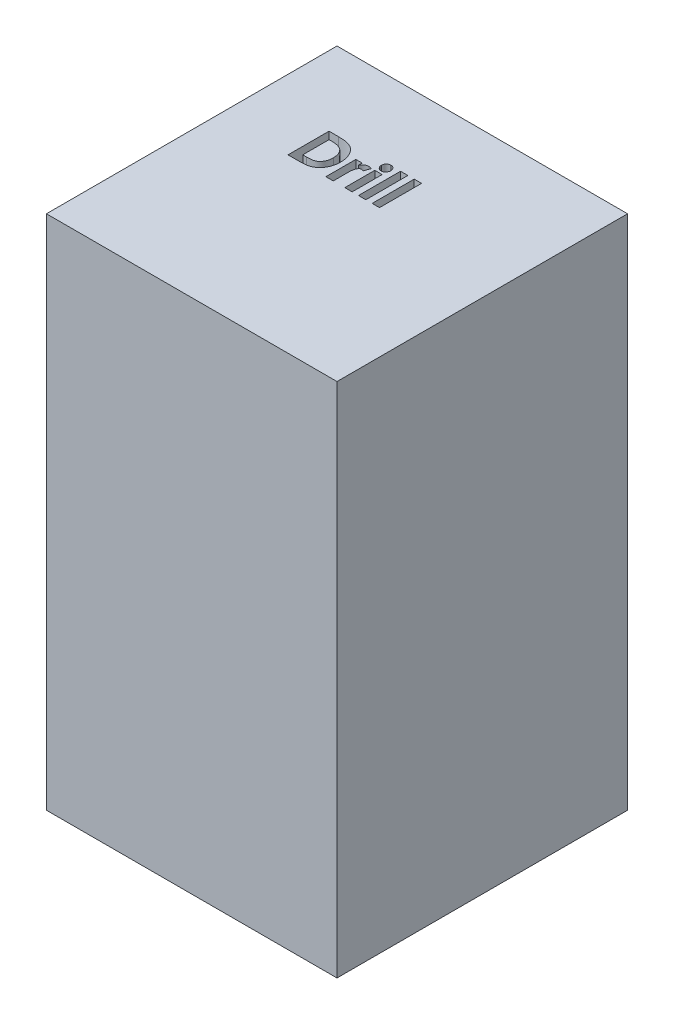
from build123d import *

# Parameters (mm, degrees)
SKETCH1_W           = 90
SKETCH1_H           = 90
BOSS_EXTRUDE1_DEPTH = 160
SKETCH2_W           = 2.27948718
SKETCH2_H           = 9.280769231
SKETCH2_W_2         = 2.279487179
SKETCH2_H_2         = 13.025641026
CUT_EXTRUDE1_DEPTH  = 150


with BuildPart() as part:
    # Sketch1 → Boss-Extrude1 (new body)
    with BuildSketch(Plane(origin=(0, 0, 0), x_dir=(1, 0, 0), z_dir=(0, 1, 0))):
        with Locations((45, 45)):
            Rectangle(SKETCH1_W, SKETCH1_H)
    extrude(amount=BOSS_EXTRUDE1_DEPTH)

    # Sketch2 → Cut-Extrude1 (cut)
    with BuildSketch(Plane(origin=(0, 160, 0), x_dir=(1, 0, 0), z_dir=(0, 1, 0))):
        with BuildLine():
            Line((21.611077672, 65.922158503), (24.483333281, 65.922158503))
            add(Edge.make_bspline(
                [(24.483333281, 65.922158503), (24.707258642, 65.920593189), (25.140108898, 65.917567417), (25.767223285, 65.88347425), (26.350359864, 65.831041379), (26.889894536, 65.758910462), (27.384721167, 65.663461507), (27.834201687, 65.543739501), (28.239844663, 65.405540361), (28.606097885, 65.242921031), (28.940451848, 65.053323041), (29.257931608, 64.842126103), (29.557913799, 64.601593454), (29.844608198, 64.336365449), (30.114314952, 64.041589823), (30.371525645, 63.722149129), (30.609942592, 63.373411035), (30.836772622, 63.003737182), (31.0419102, 62.611560926), (31.220838862, 62.200220391), (31.370728486, 61.772362706), (31.492521568, 61.327531886), (31.589604711, 60.867204634), (31.657531829, 60.390452053), (31.69952505, 59.897715535), (31.703784912, 59.563763804), (31.705949466, 59.394073568)],
                knots=[0, 0, 0, 0, 1.44355588, 2.790409838, 4.047694926, 5.217575253, 6.298404546, 7.294384826, 8.214239204, 9.058592145, 9.873746385, 10.689560431, 11.514393297, 12.350027578, 13.205127629, 14.088021785, 14.991911688, 15.926770944, 16.882954281, 17.842803888, 18.816321264, 19.80318086, 20.814351908, 21.847355356, 22.906180909, 24, 24, 24, 24], degree=3))
            add(Edge.make_bspline(
                [(31.705949466, 59.394073568), (31.700281493, 59.154629598), (31.689123756, 58.683270128), (31.595137212, 57.991555537), (31.443129146, 57.328478111), (31.229391999, 56.699224698), (30.964415152, 56.109398894), (30.647870638, 55.569402028), (30.284399734, 55.082132531), (29.8782369, 54.650016606), (29.438461471, 54.278607111), (28.981446119, 53.960522058), (28.502738681, 53.709685452), (28.080930527, 53.550617534), (27.715170235, 53.451691051), (27.394036655, 53.393224547), (27.029261674, 53.339607236), (26.617444083, 53.298172932), (26.160390436, 53.261223715), (25.656278912, 53.241146949), (25.106741679, 53.224466136), (24.725036111, 53.22294787), (24.526582479, 53.222158503)],
                knots=[0, 0, 0, 0, 1.315458931, 2.589557908, 3.828601765, 5.048913369, 6.235739168, 7.376350998, 8.481830359, 9.569842114, 10.627874879, 11.640079404, 12.624025415, 13.590060155, 14.111227486, 14.704434459, 15.382649715, 16.137166398, 16.978595427, 17.902333227, 18.909396075, 20, 20, 20, 20], degree=3))
            Line((24.526582479, 53.222158503), (21.611077672, 53.222158503))
            Line((21.611077672, 53.222158503), (21.611077672, 65.922158503))
        make_face()
        with BuildLine():
            Line((23.890564851, 63.642671324), (23.890564851, 55.501645683))
            Line((23.890564851, 55.501645683), (25.081189851, 55.501645683))
            add(Edge.make_bspline(
                [(25.081189851, 55.501645683), (25.222855941, 55.501905274), (25.495326993, 55.502404554), (25.888713514, 55.52618568), (26.252496301, 55.550055373), (26.585673943, 55.595360849), (26.890671205, 55.645827961), (27.163298221, 55.716059857), (27.409175021, 55.789832515), (27.625298266, 55.883754252), (27.823249549, 55.989469418), (28.006529826, 56.11332699), (28.183446608, 56.250866153), (28.350692293, 56.406132129), (28.508899865, 56.577068904), (28.657133269, 56.764557241), (28.797371028, 56.968025107), (28.926013504, 57.188548286), (29.043567688, 57.423798005), (29.147851421, 57.671495526), (29.234318024, 57.933703637), (29.306183771, 58.207967754), (29.357539996, 58.496675658), (29.400027477, 58.797688929), (29.421931011, 59.112200156), (29.424937135, 59.326204107), (29.426462287, 59.434778696)],
                knots=[0, 0, 0, 0, 1.50275155, 2.890291501, 4.180787663, 5.369391935, 6.45668281, 7.458360028, 8.354766181, 9.177074746, 9.954075863, 10.732690366, 11.5210699, 12.329727389, 13.151100085, 13.990027547, 14.863562427, 15.770965086, 16.696477834, 17.652329173, 18.619756807, 19.62365428, 20.657822005, 21.729286259, 22.847956731, 24, 24, 24, 24], degree=3))
            add(Edge.make_bspline(
                [(29.426462287, 59.434778696), (29.423424701, 59.601158989), (29.417501644, 59.92558767), (29.360380967, 60.398125124), (29.267399399, 60.843089927), (29.134723662, 61.258830694), (28.967481782, 61.646515876), (28.758139585, 62.002860957), (28.515706351, 62.333852044), (28.323996765, 62.528022037), (28.228205075, 62.625043119)],
                knots=[0, 0, 0, 0, 1.13821349, 2.219428113, 3.251817212, 4.244760574, 5.201143372, 6.134805572, 7.068016741, 8, 8, 8, 8], degree=3))
            add(Edge.make_bspline(
                [(28.228205075, 62.625043119), (28.133745399, 62.707718197), (27.940822207, 62.876572683), (27.602112479, 63.078903538), (27.228871901, 63.256671027), (26.812561848, 63.39762082), (26.357205771, 63.509089926), (25.86009156, 63.585967442), (25.32388137, 63.635368119), (24.952407444, 63.640184767), (24.760636966, 63.642671324)],
                knots=[0, 0, 0, 0, 0.813307809, 1.661089106, 2.549956539, 3.493439533, 4.508053171, 5.589449661, 6.755572447, 8, 8, 8, 8], degree=3))
            Line((24.760636966, 63.642671324), (23.890564851, 63.642671324))
        make_face(mode=Mode.SUBTRACT)
        with BuildLine():
            Line((33.334154595, 62.502927734), (35.288000749, 62.502927734))
            Line((35.288000749, 62.502927734), (35.288000749, 61.360640074))
            add(Edge.make_bspline(
                [(35.288000749, 61.360640074), (35.343271305, 61.462155493), (35.451299902, 61.66057159), (35.649757493, 61.926905908), (35.877753612, 62.151205239), (36.127095654, 62.338161009), (36.398539324, 62.483874674), (36.684815845, 62.587714031), (36.983476127, 62.655195223), (37.187212046, 62.662205243), (37.290184242, 62.665748247)],
                knots=[0, 0, 0, 0, 1.09866127, 2.147379032, 3.14564304, 4.131443017, 5.102343063, 6.064490016, 7.021754664, 8, 8, 8, 8], degree=3))
            add(Edge.make_bspline(
                [(37.290184242, 62.665748247), (37.364954905, 62.662247019), (37.517214674, 62.655117269), (37.749279987, 62.613671922), (37.984693596, 62.538730853), (38.139616036, 62.471256381), (38.218769979, 62.436781901)],
                knots=[0, 0, 0, 0, 0.931404136, 1.896671404, 2.925354185, 4, 4, 4, 4], degree=3))
            Line((38.218769979, 62.436781901), (37.511518377, 60.505832382))
            add(Edge.make_bspline(
                [(37.511518377, 60.505832382), (37.448300183, 60.536376356), (37.329474315, 60.593787271), (37.156959787, 60.661538064), (37.000395699, 60.702876287), (36.901136942, 60.709044312), (36.855148184, 60.711902093)],
                knots=[0, 0, 0, 0, 1.214386998, 2.282580073, 3.20428172, 4, 4, 4, 4], degree=3))
            add(Edge.make_bspline(
                [(36.855148184, 60.711902093), (36.811725854, 60.710008376), (36.726306649, 60.706283109), (36.600230293, 60.674358835), (36.481492619, 60.619306412), (36.364371666, 60.548778795), (36.258106978, 60.450740133), (36.151907928, 60.337242974), (36.058319638, 60.197115636), (35.959556851, 60.041146791), (35.875463869, 59.850241066), (35.803356726, 59.622338971), (35.739108683, 59.354803523), (35.694897257, 59.046214239), (35.65216514, 58.699557253), (35.626729934, 58.312288146), (35.607772753, 57.8856315), (35.606613649, 57.587809763), (35.606009563, 57.432595202)],
                knots=[0, 0, 0, 0, 0.544232178, 1.070598461, 1.618251235, 2.182094276, 2.777567932, 3.425210017, 4.127676488, 4.886675562, 5.738955394, 6.734782583, 7.883056018, 9.186093582, 10.642914445, 12.264202625, 14.053029461, 16, 16, 16, 16], degree=3))
            Line((35.606009563, 57.432595202), (35.613641774, 56.979750651))
            Line((35.613641774, 56.979750651), (35.613641774, 53.222158503))
            Line((35.613641774, 53.222158503), (33.334154595, 53.222158503))
            Line((33.334154595, 53.222158503), (33.334154595, 62.502927734))
        make_face()
        with BuildLine():
            add(Edge.make_bspline(
                [(40.330348505, 66.410620042), (40.428594386, 66.405799727), (40.62150964, 66.396334575), (40.897886993, 66.304070393), (41.151545391, 66.159264517), (41.375786449, 65.960587403), (41.562289193, 65.723330591), (41.704784215, 65.457705815), (41.784162256, 65.163402119), (41.795186692, 64.960100203), (41.800821261, 64.856192959)],
                knots=[0, 0, 0, 0, 0.989868614, 1.943702388, 2.910836514, 3.924849579, 4.949916355, 5.946401046, 6.950409252, 8, 8, 8, 8], degree=3))
            add(Edge.make_bspline(
                [(41.800821261, 64.856192959), (41.795388287, 64.753051453), (41.784801879, 64.552075317), (41.702957281, 64.261766931), (41.566181513, 63.996271169), (41.378168214, 63.762538061), (41.156358222, 63.56706076), (40.908242454, 63.41962602), (40.634513598, 63.332494474), (40.444591807, 63.322238088), (40.348156999, 63.317030298)],
                knots=[0, 0, 0, 0, 1.05296456, 2.051751585, 3.055639087, 4.085634717, 5.099016424, 6.062201612, 7.016062274, 8, 8, 8, 8], degree=3))
            add(Edge.make_bspline(
                [(40.348156999, 63.317030298), (40.249053512, 63.321833381), (40.054459903, 63.331264425), (39.775815687, 63.423744483), (39.518774135, 63.567409919), (39.295505833, 63.770146314), (39.106867216, 64.009089016), (38.970596432, 64.280897766), (38.885355686, 64.577213904), (38.875237684, 64.783526859), (38.870052031, 64.889265875)],
                knots=[0, 0, 0, 0, 0.989065327, 1.942068821, 2.907541208, 3.917690034, 4.939857478, 5.938239964, 6.943311734, 8, 8, 8, 8], degree=3))
            add(Edge.make_bspline(
                [(38.870052031, 64.889265875), (38.87569544, 64.990655977), (38.886781102, 65.189822194), (38.966634626, 65.477582657), (39.105862243, 65.738741864), (39.291021589, 65.971655469), (39.513293056, 66.166626507), (39.766799179, 66.307034534), (40.041316502, 66.395487942), (40.233009707, 66.405523927), (40.330348505, 66.410620042)],
                knots=[0, 0, 0, 0, 1.038616768, 2.040212704, 3.031499824, 4.052181184, 5.074969369, 6.039807101, 7.004644834, 8, 8, 8, 8], degree=3))
        make_face()
        with Locations((40.335436646, 57.862543118)):
            Rectangle(SKETCH2_W, SKETCH2_H)
        with Locations((44.56876998, 59.734979016)):
            Rectangle(SKETCH2_W_2, SKETCH2_H_2)
        with Locations((48.802103313, 59.734979016)):
            Rectangle(SKETCH2_W_2, SKETCH2_H_2)
    extrude(amount=-CUT_EXTRUDE1_DEPTH, mode=Mode.SUBTRACT)


solid = part.part
